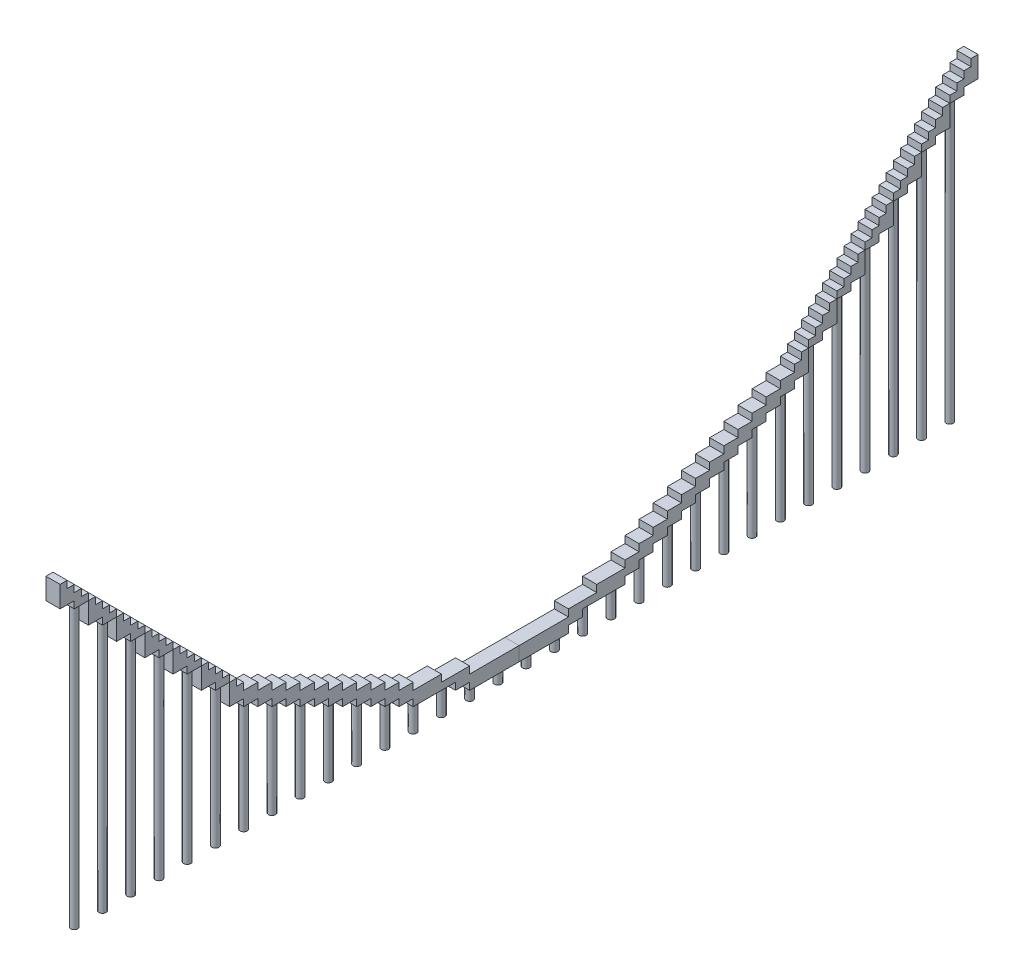
from build123d import *

# Parameters (mm, degrees)
AUFSATZ_LINEAR_AUSTRAGEN1_DEPTH    = 0.5
SKIZZE1_W                          = 1
SKIZZE1_H                          = 1
AUFSATZ_LINEAR_AUSTRAGEN1_2_DEPTH  = 0.5
AUFSATZ_LINEAR_AUSTRAGEN1_3_DEPTH  = 0.5
AUFSATZ_LINEAR_AUSTRAGEN1_4_DEPTH  = 0.5
AUFSATZ_LINEAR_AUSTRAGEN1_5_DEPTH  = 0.5
AUFSATZ_LINEAR_AUSTRAGEN1_6_DEPTH  = 0.5
AUFSATZ_LINEAR_AUSTRAGEN1_7_DEPTH  = 0.5
AUFSATZ_LINEAR_AUSTRAGEN1_8_DEPTH  = 0.5
AUFSATZ_LINEAR_AUSTRAGEN1_9_DEPTH  = 0.5
AUFSATZ_LINEAR_AUSTRAGEN1_10_DEPTH = 0.5
AUFSATZ_LINEAR_AUSTRAGEN1_11_DEPTH = 0.5
AUFSATZ_LINEAR_AUSTRAGEN1_12_DEPTH = 0.5
AUFSATZ_LINEAR_AUSTRAGEN1_13_DEPTH = 0.5
AUFSATZ_LINEAR_AUSTRAGEN1_14_DEPTH = 0.5
SKIZZE2_W                          = 1
SKIZZE2_H                          = 0.5
AUFSATZ_LINEAR_AUSTRAGEN2_DEPTH    = 1
AUFSATZ_LINEAR_AUSTRAGEN3_REACH    = 41.249
SKIZZE4_R                          = 0.25
SKIZZE5_W                          = 0.5
SKIZZE5_H                          = 0.5
SCHNITT_LINEAR_AUSTRAGEN1_DEPTH    = 40.258756985


with BuildPart() as part:
    # Skizze1 → Aufsatz-Linear austragen1 (new, symmetric)
    with BuildSketch(Plane(origin=(0, 0, 0), x_dir=(0, 0, -1), z_dir=(1, 0, 0))):
        Polygon((0, 1), (0, 2), (-3.5, 2), (-3.5, 2.5), (-5.5, 2.5), (-5.5, 3), (-7.5, 3), (-7.5, 3.5), (-8.5, 3.5), (-8.5, 4), (-9.5, 4), (-9.5, 4.5), (-10.5, 4.5), (-10.5, 5), (-11.5, 5), (-11.5, 5.5), (-12.5, 5.5), (-12.5, 6), (-13.5, 6), (-13.5, 6.5), (-14.5, 6.5), (-14.5, 7), (-15.5, 7), (-15.5, 7.5), (-16.5, 7.5), (-16.5, 8), (-17.5, 8), (-17.5, 8.5), (-18.5, 8.5), (-18.5, 9), (-19.5, 9), (-19.5, 8), (-18.5, 8), (-18.5, 7.5), (-17.5, 7.5), (-17.5, 7), (-16.5, 7), (-16.5, 6.5), (-15.5, 6.5), (-15.5, 6), (-14.5, 6), (-14.5, 5.5), (-13.5, 5.5), (-13.5, 5), (-12.5, 5), (-12.5, 4.5), (-11.5, 4.5), (-11.5, 4), (-10.5, 4), (-10.5, 3.5), (-9.5, 3.5), (-9.5, 3), (-8.5, 3), (-8.5, 2.5), (-7.5, 2.5), (-7.5, 2), (-4.5, 2), (-4.5, 1.5), (-3.5, 1.5), (-3.5, 1), align=None)
    extrude(amount=AUFSATZ_LINEAR_AUSTRAGEN1_DEPTH, both=True)



with BuildPart() as body_2:
    # Skizze1 → Aufsatz-Linear austragen1 2 (new, symmetric)
    with BuildSketch(Plane(origin=(0, 0, 0), x_dir=(0, 0, -1), z_dir=(1, 0, 0))):
        with Locations((-32, 21.5)):
            Rectangle(SKIZZE1_W, SKIZZE1_H)
    extrude(amount=AUFSATZ_LINEAR_AUSTRAGEN1_2_DEPTH, both=True)


with BuildPart() as body_3:
    # Skizze1 → Aufsatz-Linear austragen1 3 (new, symmetric)
    with BuildSketch(Plane(origin=(0, 0, 0), x_dir=(0, 0, -1), z_dir=(1, 0, 0))):
        with Locations((-31, 20.5)):
            Rectangle(SKIZZE1_W, SKIZZE1_H)
    extrude(amount=AUFSATZ_LINEAR_AUSTRAGEN1_3_DEPTH, both=True)


with BuildPart() as body_4:
    # Skizze1 → Aufsatz-Linear austragen1 4 (new, symmetric)
    with BuildSketch(Plane(origin=(0, 0, 0), x_dir=(0, 0, -1), z_dir=(1, 0, 0))):
        with Locations((-30, 19.5)):
            Rectangle(SKIZZE1_W, SKIZZE1_H)
    extrude(amount=AUFSATZ_LINEAR_AUSTRAGEN1_4_DEPTH, both=True)


with BuildPart() as body_5:
    # Skizze1 → Aufsatz-Linear austragen1 5 (new, symmetric)
    with BuildSketch(Plane(origin=(0, 0, 0), x_dir=(0, 0, -1), z_dir=(1, 0, 0))):
        with Locations((-29, 18.5)):
            Rectangle(SKIZZE1_W, SKIZZE1_H)
    extrude(amount=AUFSATZ_LINEAR_AUSTRAGEN1_5_DEPTH, both=True)


with BuildPart() as body_6:
    # Skizze1 → Aufsatz-Linear austragen1 6 (new, symmetric)
    with BuildSketch(Plane(origin=(0, 0, 0), x_dir=(0, 0, -1), z_dir=(1, 0, 0))):
        with Locations((-28, 17.5)):
            Rectangle(SKIZZE1_W, SKIZZE1_H)
    extrude(amount=AUFSATZ_LINEAR_AUSTRAGEN1_6_DEPTH, both=True)


with BuildPart() as body_7:
    # Skizze1 → Aufsatz-Linear austragen1 7 (new, symmetric)
    with BuildSketch(Plane(origin=(0, 0, 0), x_dir=(0, 0, -1), z_dir=(1, 0, 0))):
        with Locations((-27, 16.5)):
            Rectangle(SKIZZE1_W, SKIZZE1_H)
    extrude(amount=AUFSATZ_LINEAR_AUSTRAGEN1_7_DEPTH, both=True)


with BuildPart() as body_8:
    # Skizze1 → Aufsatz-Linear austragen1 8 (new, symmetric)
    with BuildSketch(Plane(origin=(0, 0, 0), x_dir=(0, 0, -1), z_dir=(1, 0, 0))):
        with Locations((-26, 15.5)):
            Rectangle(SKIZZE1_W, SKIZZE1_H)
    extrude(amount=AUFSATZ_LINEAR_AUSTRAGEN1_8_DEPTH, both=True)


with BuildPart() as body_9:
    # Skizze1 → Aufsatz-Linear austragen1 9 (new, symmetric)
    with BuildSketch(Plane(origin=(0, 0, 0), x_dir=(0, 0, -1), z_dir=(1, 0, 0))):
        with Locations((-25, 14.5)):
            Rectangle(SKIZZE1_W, SKIZZE1_H)
    extrude(amount=AUFSATZ_LINEAR_AUSTRAGEN1_9_DEPTH, both=True)


with BuildPart() as body_10:
    # Skizze1 → Aufsatz-Linear austragen1 10 (new, symmetric)
    with BuildSketch(Plane(origin=(0, 0, 0), x_dir=(0, 0, -1), z_dir=(1, 0, 0))):
        with Locations((-24, 13.5)):
            Rectangle(SKIZZE1_W, SKIZZE1_H)
    extrude(amount=AUFSATZ_LINEAR_AUSTRAGEN1_10_DEPTH, both=True)


with BuildPart() as body_11:
    # Skizze1 → Aufsatz-Linear austragen1 11 (new, symmetric)
    with BuildSketch(Plane(origin=(0, 0, 0), x_dir=(0, 0, -1), z_dir=(1, 0, 0))):
        with Locations((-23, 12.5)):
            Rectangle(SKIZZE1_W, SKIZZE1_H)
    extrude(amount=AUFSATZ_LINEAR_AUSTRAGEN1_11_DEPTH, both=True)


with BuildPart() as body_12:
    # Skizze1 → Aufsatz-Linear austragen1 12 (new, symmetric)
    with BuildSketch(Plane(origin=(0, 0, 0), x_dir=(0, 0, -1), z_dir=(1, 0, 0))):
        with Locations((-22, 11.5)):
            Rectangle(SKIZZE1_W, SKIZZE1_H)
    extrude(amount=AUFSATZ_LINEAR_AUSTRAGEN1_12_DEPTH, both=True)


with BuildPart() as body_13:
    # Skizze1 → Aufsatz-Linear austragen1 13 (new, symmetric)
    with BuildSketch(Plane(origin=(0, 0, 0), x_dir=(0, 0, -1), z_dir=(1, 0, 0))):
        with Locations((-21, 10.5)):
            Rectangle(SKIZZE1_W, SKIZZE1_H)
    extrude(amount=AUFSATZ_LINEAR_AUSTRAGEN1_13_DEPTH, both=True)


with BuildPart() as body_14:
    # Skizze1 → Aufsatz-Linear austragen1 14 (new, symmetric)
    with BuildSketch(Plane(origin=(0, 0, 0), x_dir=(0, 0, -1), z_dir=(1, 0, 0))):
        with Locations((-20, 9.5)):
            Rectangle(SKIZZE1_W, SKIZZE1_H)
    extrude(amount=AUFSATZ_LINEAR_AUSTRAGEN1_14_DEPTH, both=True)


with BuildPart() as part_1:
    add(part.part)

    add(body_2.part)  # Aufsatz-Linear austragen2 merges body 2

    add(body_3.part)  # Aufsatz-Linear austragen2 merges body 3

    add(body_4.part)  # Aufsatz-Linear austragen2 merges body 4

    add(body_5.part)  # Aufsatz-Linear austragen2 merges body 5

    add(body_6.part)  # Aufsatz-Linear austragen2 merges body 6

    add(body_7.part)  # Aufsatz-Linear austragen2 merges body 7

    add(body_8.part)  # Aufsatz-Linear austragen2 merges body 8

    add(body_9.part)  # Aufsatz-Linear austragen2 merges body 9

    add(body_10.part)  # Aufsatz-Linear austragen2 merges body 10

    add(body_11.part)  # Aufsatz-Linear austragen2 merges body 11

    add(body_12.part)  # Aufsatz-Linear austragen2 merges body 12

    add(body_13.part)  # Aufsatz-Linear austragen2 merges body 13

    add(body_14.part)  # Aufsatz-Linear austragen2 merges body 14
    # Skizze2 → Aufsatz-Linear austragen2 (add)
    with BuildSketch(Plane(origin=(0.5, 0, 0), x_dir=(0, 0, -1), z_dir=(1, 0, 0))):
        with Locations((-32, 20.75)):
            Rectangle(SKIZZE2_W, SKIZZE2_H)
        with Locations((-30, 18.75)):
            Rectangle(SKIZZE2_W, SKIZZE2_H)
        with Locations((-28, 16.75)):
            Rectangle(SKIZZE2_W, SKIZZE2_H)
        with Locations((-26, 14.75)):
            Rectangle(SKIZZE2_W, SKIZZE2_H)
        with Locations((-24, 12.75)):
            Rectangle(SKIZZE2_W, SKIZZE2_H)
        with Locations((-22, 10.75)):
            Rectangle(SKIZZE2_W, SKIZZE2_H)
        with Locations((-20, 8.75)):
            Rectangle(SKIZZE2_W, SKIZZE2_H)
    extrude(amount=-AUFSATZ_LINEAR_AUSTRAGEN2_DEPTH)

    # Skizze4 → Aufsatz-Linear austragen3 (add, up to next)
    with BuildSketch(Plane(origin=(0, 0, 0), x_dir=(1, 0, 0), z_dir=(0, 1, 0)), mode=Mode.PRIVATE) as aufsatz_linear_austragen3_sk1:
        with Locations((0, -31)):
            Circle(SKIZZE4_R)
    aufsatz_linear_austragen3_tool1 = extrude(aufsatz_linear_austragen3_sk1.sketch, amount=AUFSATZ_LINEAR_AUSTRAGEN3_REACH, mode=Mode.PRIVATE) - part_1.part
    # Skizze4 → Aufsatz-Linear austragen3 (add, up to next)
    with BuildSketch(Plane(origin=(0, 0, 0), x_dir=(1, 0, 0), z_dir=(0, 1, 0)), mode=Mode.PRIVATE) as aufsatz_linear_austragen3_sk2:
        with Locations((0, -29)):
            Circle(SKIZZE4_R)
    aufsatz_linear_austragen3_tool2 = extrude(aufsatz_linear_austragen3_sk2.sketch, amount=AUFSATZ_LINEAR_AUSTRAGEN3_REACH, mode=Mode.PRIVATE) - part_1.part
    # Skizze4 → Aufsatz-Linear austragen3 (add, up to next)
    with BuildSketch(Plane(origin=(0, 0, 0), x_dir=(1, 0, 0), z_dir=(0, 1, 0)), mode=Mode.PRIVATE) as aufsatz_linear_austragen3_sk3:
        with Locations((0, -27)):
            Circle(SKIZZE4_R)
    aufsatz_linear_austragen3_tool3 = extrude(aufsatz_linear_austragen3_sk3.sketch, amount=AUFSATZ_LINEAR_AUSTRAGEN3_REACH, mode=Mode.PRIVATE) - part_1.part
    # Skizze4 → Aufsatz-Linear austragen3 (add, up to next)
    with BuildSketch(Plane(origin=(0, 0, 0), x_dir=(1, 0, 0), z_dir=(0, 1, 0)), mode=Mode.PRIVATE) as aufsatz_linear_austragen3_sk4:
        with Locations((0, -25)):
            Circle(SKIZZE4_R)
    aufsatz_linear_austragen3_tool4 = extrude(aufsatz_linear_austragen3_sk4.sketch, amount=AUFSATZ_LINEAR_AUSTRAGEN3_REACH, mode=Mode.PRIVATE) - part_1.part
    # Skizze4 → Aufsatz-Linear austragen3 (add, up to next)
    with BuildSketch(Plane(origin=(0, 0, 0), x_dir=(1, 0, 0), z_dir=(0, 1, 0)), mode=Mode.PRIVATE) as aufsatz_linear_austragen3_sk5:
        with Locations((0, -23)):
            Circle(SKIZZE4_R)
    aufsatz_linear_austragen3_tool5 = extrude(aufsatz_linear_austragen3_sk5.sketch, amount=AUFSATZ_LINEAR_AUSTRAGEN3_REACH, mode=Mode.PRIVATE) - part_1.part
    # Skizze4 → Aufsatz-Linear austragen3 (add, up to next)
    with BuildSketch(Plane(origin=(0, 0, 0), x_dir=(1, 0, 0), z_dir=(0, 1, 0)), mode=Mode.PRIVATE) as aufsatz_linear_austragen3_sk6:
        with Locations((0, -21)):
            Circle(SKIZZE4_R)
    aufsatz_linear_austragen3_tool6 = extrude(aufsatz_linear_austragen3_sk6.sketch, amount=AUFSATZ_LINEAR_AUSTRAGEN3_REACH, mode=Mode.PRIVATE) - part_1.part
    # Skizze4 → Aufsatz-Linear austragen3 (add, up to next)
    with BuildSketch(Plane(origin=(0, 0, 0), x_dir=(1, 0, 0), z_dir=(0, 1, 0)), mode=Mode.PRIVATE) as aufsatz_linear_austragen3_sk7:
        with Locations((0, -19)):
            Circle(SKIZZE4_R)
    aufsatz_linear_austragen3_tool7 = extrude(aufsatz_linear_austragen3_sk7.sketch, amount=AUFSATZ_LINEAR_AUSTRAGEN3_REACH, mode=Mode.PRIVATE) - part_1.part
    # Skizze4 → Aufsatz-Linear austragen3 (add, up to next)
    with BuildSketch(Plane(origin=(0, 0, 0), x_dir=(1, 0, 0), z_dir=(0, 1, 0)), mode=Mode.PRIVATE) as aufsatz_linear_austragen3_sk8:
        with Locations((0, -17)):
            Circle(SKIZZE4_R)
    aufsatz_linear_austragen3_tool8 = extrude(aufsatz_linear_austragen3_sk8.sketch, amount=AUFSATZ_LINEAR_AUSTRAGEN3_REACH, mode=Mode.PRIVATE) - part_1.part
    # Skizze4 → Aufsatz-Linear austragen3 (add, up to next)
    with BuildSketch(Plane(origin=(0, 0, 0), x_dir=(1, 0, 0), z_dir=(0, 1, 0)), mode=Mode.PRIVATE) as aufsatz_linear_austragen3_sk9:
        with Locations((0, -15)):
            Circle(SKIZZE4_R)
    aufsatz_linear_austragen3_tool9 = extrude(aufsatz_linear_austragen3_sk9.sketch, amount=AUFSATZ_LINEAR_AUSTRAGEN3_REACH, mode=Mode.PRIVATE) - part_1.part
    # Skizze4 → Aufsatz-Linear austragen3 (add, up to next)
    with BuildSketch(Plane(origin=(0, 0, 0), x_dir=(1, 0, 0), z_dir=(0, 1, 0)), mode=Mode.PRIVATE) as aufsatz_linear_austragen3_sk10:
        with Locations((0, -13)):
            Circle(SKIZZE4_R)
    aufsatz_linear_austragen3_tool10 = extrude(aufsatz_linear_austragen3_sk10.sketch, amount=AUFSATZ_LINEAR_AUSTRAGEN3_REACH, mode=Mode.PRIVATE) - part_1.part
    # Skizze4 → Aufsatz-Linear austragen3 (add, up to next)
    with BuildSketch(Plane(origin=(0, 0, 0), x_dir=(1, 0, 0), z_dir=(0, 1, 0)), mode=Mode.PRIVATE) as aufsatz_linear_austragen3_sk11:
        with Locations((0, -11)):
            Circle(SKIZZE4_R)
    aufsatz_linear_austragen3_tool11 = extrude(aufsatz_linear_austragen3_sk11.sketch, amount=AUFSATZ_LINEAR_AUSTRAGEN3_REACH, mode=Mode.PRIVATE) - part_1.part
    # Skizze4 → Aufsatz-Linear austragen3 (add, up to next)
    with BuildSketch(Plane(origin=(0, 0, 0), x_dir=(1, 0, 0), z_dir=(0, 1, 0)), mode=Mode.PRIVATE) as aufsatz_linear_austragen3_sk12:
        with Locations((0, -9)):
            Circle(SKIZZE4_R)
    aufsatz_linear_austragen3_tool12 = extrude(aufsatz_linear_austragen3_sk12.sketch, amount=AUFSATZ_LINEAR_AUSTRAGEN3_REACH, mode=Mode.PRIVATE) - part_1.part
    # Skizze4 → Aufsatz-Linear austragen3 (add, up to next)
    with BuildSketch(Plane(origin=(0, 0, 0), x_dir=(1, 0, 0), z_dir=(0, 1, 0)), mode=Mode.PRIVATE) as aufsatz_linear_austragen3_sk13:
        with Locations((0, -7)):
            Circle(SKIZZE4_R)
    aufsatz_linear_austragen3_tool13 = extrude(aufsatz_linear_austragen3_sk13.sketch, amount=AUFSATZ_LINEAR_AUSTRAGEN3_REACH, mode=Mode.PRIVATE) - part_1.part
    # Skizze4 → Aufsatz-Linear austragen3 (add, up to next)
    with BuildSketch(Plane(origin=(0, 0, 0), x_dir=(1, 0, 0), z_dir=(0, 1, 0)), mode=Mode.PRIVATE) as aufsatz_linear_austragen3_sk14:
        with Locations((0, -5)):
            Circle(SKIZZE4_R)
    aufsatz_linear_austragen3_tool14 = extrude(aufsatz_linear_austragen3_sk14.sketch, amount=AUFSATZ_LINEAR_AUSTRAGEN3_REACH, mode=Mode.PRIVATE) - part_1.part
    # Skizze4 → Aufsatz-Linear austragen3 (add, up to next)
    with BuildSketch(Plane(origin=(0, 0, 0), x_dir=(1, 0, 0), z_dir=(0, 1, 0)), mode=Mode.PRIVATE) as aufsatz_linear_austragen3_sk15:
        with Locations((0, -3)):
            Circle(SKIZZE4_R)
    aufsatz_linear_austragen3_tool15 = extrude(aufsatz_linear_austragen3_sk15.sketch, amount=AUFSATZ_LINEAR_AUSTRAGEN3_REACH, mode=Mode.PRIVATE) - part_1.part
    # Skizze4 → Aufsatz-Linear austragen3 (add, up to next)
    with BuildSketch(Plane(origin=(0, 0, 0), x_dir=(1, 0, 0), z_dir=(0, 1, 0)), mode=Mode.PRIVATE) as aufsatz_linear_austragen3_sk16:
        with Locations((0, -1)):
            Circle(SKIZZE4_R)
    aufsatz_linear_austragen3_tool16 = extrude(aufsatz_linear_austragen3_sk16.sketch, amount=AUFSATZ_LINEAR_AUSTRAGEN3_REACH, mode=Mode.PRIVATE) - part_1.part
    add(aufsatz_linear_austragen3_tool1.solids().sort_by_distance((0, 0, 31))[0])
    add(aufsatz_linear_austragen3_tool2.solids().sort_by_distance((0, 0, 29))[0])
    add(aufsatz_linear_austragen3_tool3.solids().sort_by_distance((0, 0, 27))[0])
    add(aufsatz_linear_austragen3_tool4.solids().sort_by_distance((0, 0, 25))[0])
    add(aufsatz_linear_austragen3_tool5.solids().sort_by_distance((0, 0, 23))[0])
    add(aufsatz_linear_austragen3_tool6.solids().sort_by_distance((0, 0, 21))[0])
    add(aufsatz_linear_austragen3_tool7.solids().sort_by_distance((0, 0, 19))[0])
    add(aufsatz_linear_austragen3_tool8.solids().sort_by_distance((0, 0, 17))[0])
    add(aufsatz_linear_austragen3_tool9.solids().sort_by_distance((0, 0, 15))[0])
    add(aufsatz_linear_austragen3_tool10.solids().sort_by_distance((0, 0, 13))[0])
    add(aufsatz_linear_austragen3_tool11.solids().sort_by_distance((0, 0, 11))[0])
    add(aufsatz_linear_austragen3_tool12.solids().sort_by_distance((0, 0, 9))[0])
    add(aufsatz_linear_austragen3_tool13.solids().sort_by_distance((0, 0, 7))[0])
    add(aufsatz_linear_austragen3_tool14.solids().sort_by_distance((0, 0, 5))[0])
    add(aufsatz_linear_austragen3_tool15.solids().sort_by_distance((0, 0, 3))[0])
    add(aufsatz_linear_austragen3_tool16.solids().sort_by_distance((0, 0, 1))[0])

    # Skizze5 → Schnitt-Linear austragen1 (cut, through all)
    with BuildSketch(Plane(origin=(0.5, 0, 0), x_dir=(0, 0, -1), z_dir=(1, 0, 0))):
        with Locations((-31.75, 21.75)):
            Rectangle(SKIZZE5_W, SKIZZE5_H)
        with Locations((-30.75, 20.75)):
            Rectangle(SKIZZE5_W, SKIZZE5_H)
        with Locations((-29.75, 19.75)):
            Rectangle(SKIZZE5_W, SKIZZE5_H)
        with Locations((-28.75, 18.75)):
            Rectangle(SKIZZE5_W, SKIZZE5_H)
        with Locations((-27.75, 17.75)):
            Rectangle(SKIZZE5_W, SKIZZE5_H)
        with Locations((-26.75, 16.75)):
            Rectangle(SKIZZE5_W, SKIZZE5_H)
        with Locations((-25.75, 15.75)):
            Rectangle(SKIZZE5_W, SKIZZE5_H)
        with Locations((-24.75, 14.75)):
            Rectangle(SKIZZE5_W, SKIZZE5_H)
        with Locations((-23.75, 13.75)):
            Rectangle(SKIZZE5_W, SKIZZE5_H)
        with Locations((-22.75, 12.75)):
            Rectangle(SKIZZE5_W, SKIZZE5_H)
        with Locations((-21.75, 11.75)):
            Rectangle(SKIZZE5_W, SKIZZE5_H)
        with Locations((-20.75, 10.75)):
            Rectangle(SKIZZE5_W, SKIZZE5_H)
        with Locations((-19.75, 9.75)):
            Rectangle(SKIZZE5_W, SKIZZE5_H)
    extrude(amount=-SCHNITT_LINEAR_AUSTRAGEN1_DEPTH, mode=Mode.SUBTRACT)


with BuildPart() as body_2_2:
    # Spiegeln1: mirrored copy
    add(part_1.part.mirror(Plane(origin=(0.5, 0, 0), x_dir=(1, 0, 0), z_dir=(0, 0, -1))))


solid = Compound([part_1.part, body_2_2.part])
